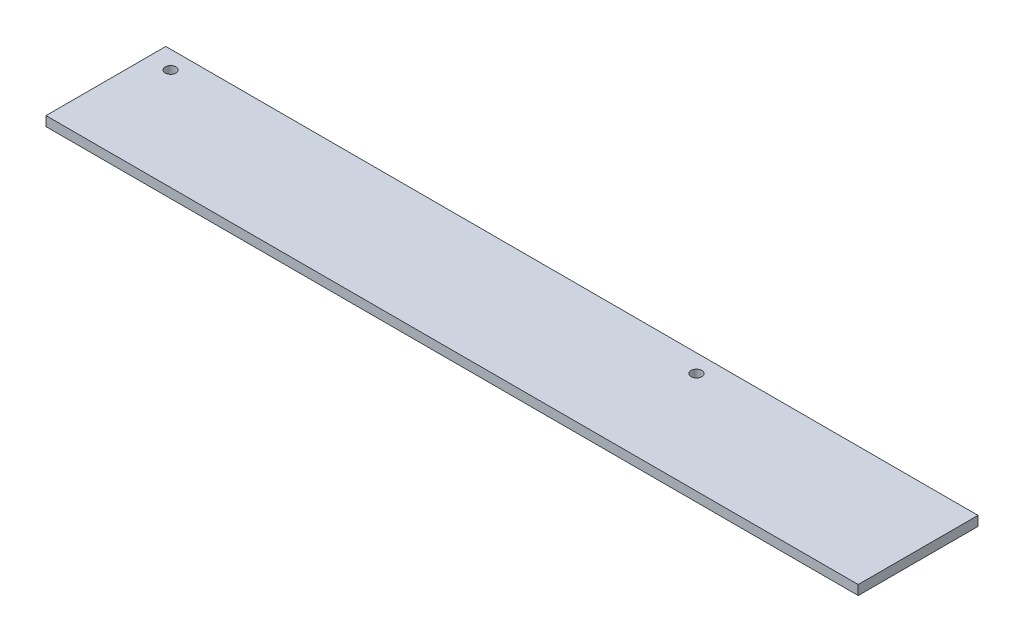
from build123d import *

# Parameters (mm, degrees)
SKETCH_1_W          = 50
SKETCH_1_H          = 4
EXTRUDE_1_DEPTH     = 339
SKETCH_2_R          = 2.25
CUT_EXTRUDE_1_DEPTH = 5


with BuildPart() as part:
    # Эскиз1 → Бобышка-Вытянуть1 (new body)
    with BuildSketch(Plane(origin=(0, 0, 0), x_dir=(0, 0, -1), z_dir=(1, 0, 0))):
        Rectangle(SKETCH_1_W, SKETCH_1_H)
    extrude(amount=EXTRUDE_1_DEPTH)

    # Эскиз2 → Вырез-Вытянуть1 (cut, through all)
    with BuildSketch(Plane(origin=(0, 2, 0), x_dir=(1, 0, 0), z_dir=(0, 1, 0))):
        with Locations((9.5, 17.5)):
            Circle(SKETCH_2_R)
        with Locations((229, 17.5)):
            Circle(SKETCH_2_R)
    extrude(amount=-CUT_EXTRUDE_1_DEPTH, mode=Mode.SUBTRACT)


solid = part.part
